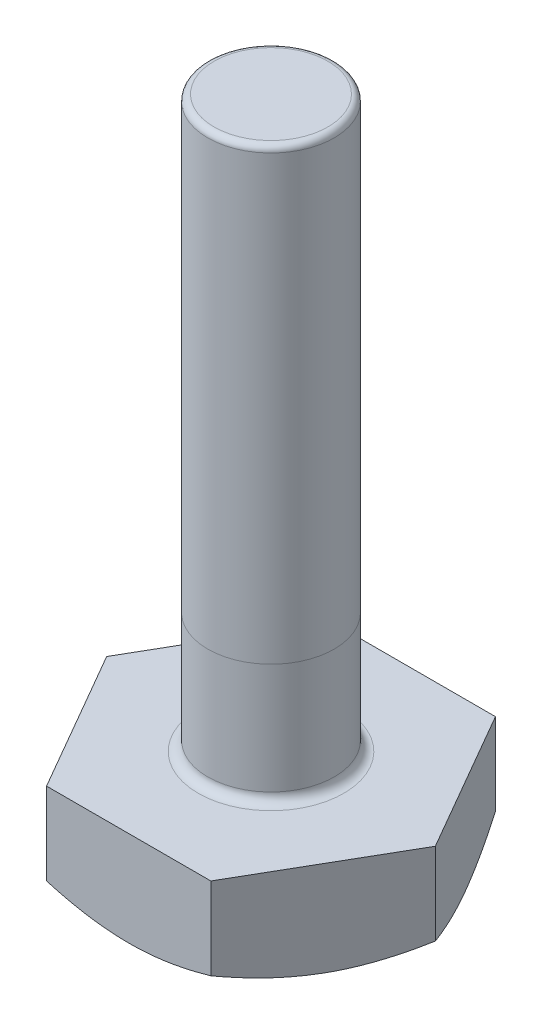
from build123d import *

# Parameters (mm, degrees)
BOSS_EXTRUDE2_DEPTH = 1.5
SKETCH2_OUTSIDE_W   = 13.8
SKETCH2_OUTSIDE_H   = 13.104
SKETCH2_OUTSIDE_R   = 2.25
CUT_EXTRUDE1_DEPTH  = 1.5
CUT_EXTRUDE1_TAPER  = 60
SKETCH3_R           = 1
BOSS_EXTRUDE3_DEPTH = 9
FILLET1_R           = 0.1
FILLET2_R           = 0.15


with BuildPart() as part:
    # Sketch1 → Boss-Extrude2 (new body)
    with BuildSketch(Plane(origin=(0, 0, 0), x_dir=(1, 0, 0), z_dir=(0, 1, 0))):
        Polygon((2.598076211, 0), (1.299038106, 2.25), (-1.299038106, 2.25), (-2.598076211, 0), (-1.299038106, -2.25), (1.299038106, -2.25), align=None)
    extrude(amount=BOSS_EXTRUDE2_DEPTH)

    # Sketch2 outside → Cut-Extrude1 (cut)
    with BuildSketch(Plane(origin=(0, 0, 0), x_dir=(1, 0, 0), z_dir=(0, 1, 0))):
        Rectangle(SKETCH2_OUTSIDE_W, SKETCH2_OUTSIDE_H)
        Circle(SKETCH2_OUTSIDE_R, mode=Mode.SUBTRACT)
    extrude(amount=CUT_EXTRUDE1_DEPTH, taper=CUT_EXTRUDE1_TAPER, mode=Mode.SUBTRACT)

    # Sketch3 → Boss-Extrude3 (add)
    with BuildSketch(Plane(origin=(0, 1.5, 0), x_dir=(1, 0, 0), z_dir=(0, 1, 0))):
        Circle(SKETCH3_R)
    extrude(amount=BOSS_EXTRUDE3_DEPTH)

    # Fillet1
    fillet1_edges = [part.edges().sort_by_distance(p)[0] for p in [
        (-1, 10.5, 0),
    ]]
    fillet(fillet1_edges, radius=FILLET1_R)

    # Fillet2
    fillet2_edges = [part.edges().sort_by_distance(p)[0] for p in [
        (-1, 1.5, 0),
    ]]
    fillet(fillet2_edges, radius=FILLET2_R)


solid = part.part
